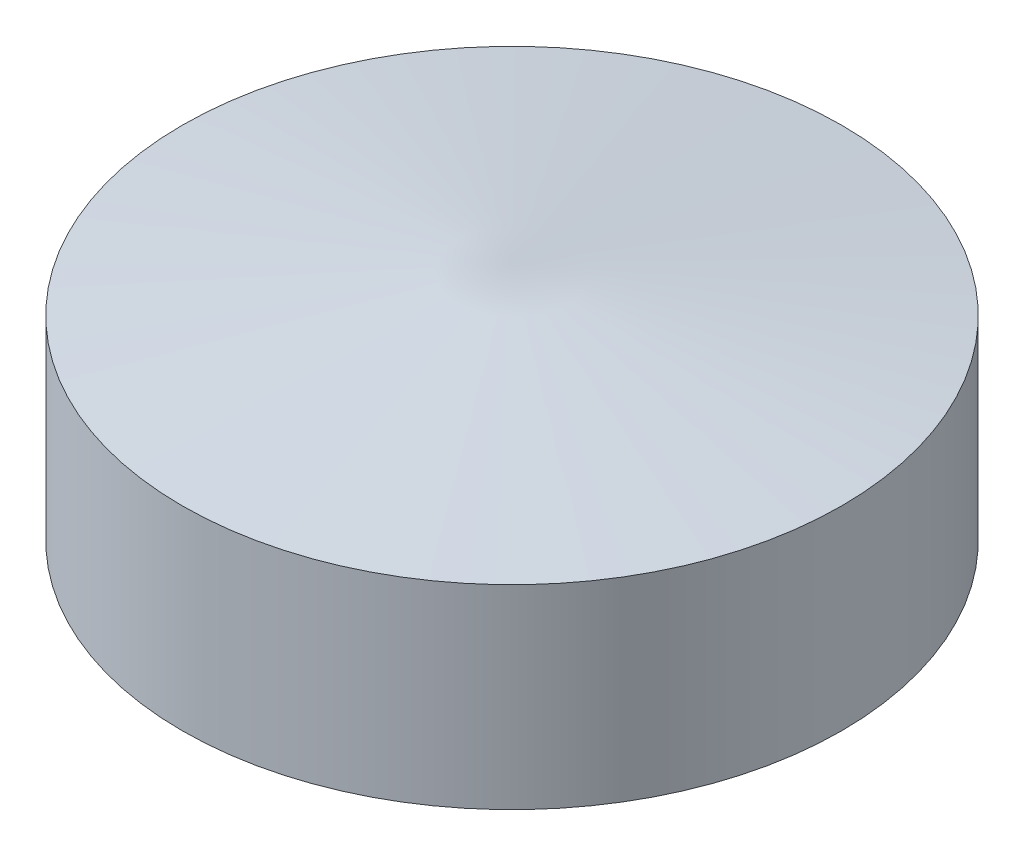
from build123d import *

# Parameters (mm, degrees)
SKETCH3_R          = 1.5
CUT_EXTRUDE1_DEPTH = 10


with BuildPart() as part:
    # Sketch2 → Revolve1 (revolve)
    with BuildSketch(Plane.XY, mode=Mode.PRIVATE) as revolve1_sk:
        Polygon((0, 0), (22, 0), (22, 13), (0, 16), align=None)
    revolve(revolve1_sk.sketch.rotate(Axis((0, 0, 0), (0, 1, 0)), 90), axis=Axis((0, 0, 0), (0, 1, 0)))  # turned: the seam where the file's is

    # Sketch3 → Cut-Extrude1 (cut)
    with BuildSketch(Plane(origin=(0, 0, 0), x_dir=(1, 0, 0), z_dir=(0, 1, 0))):
        with Locations((-22, 0)):
            Circle(SKETCH3_R)
    extrude(amount=CUT_EXTRUDE1_DEPTH, mode=Mode.SUBTRACT)


solid = part.part
